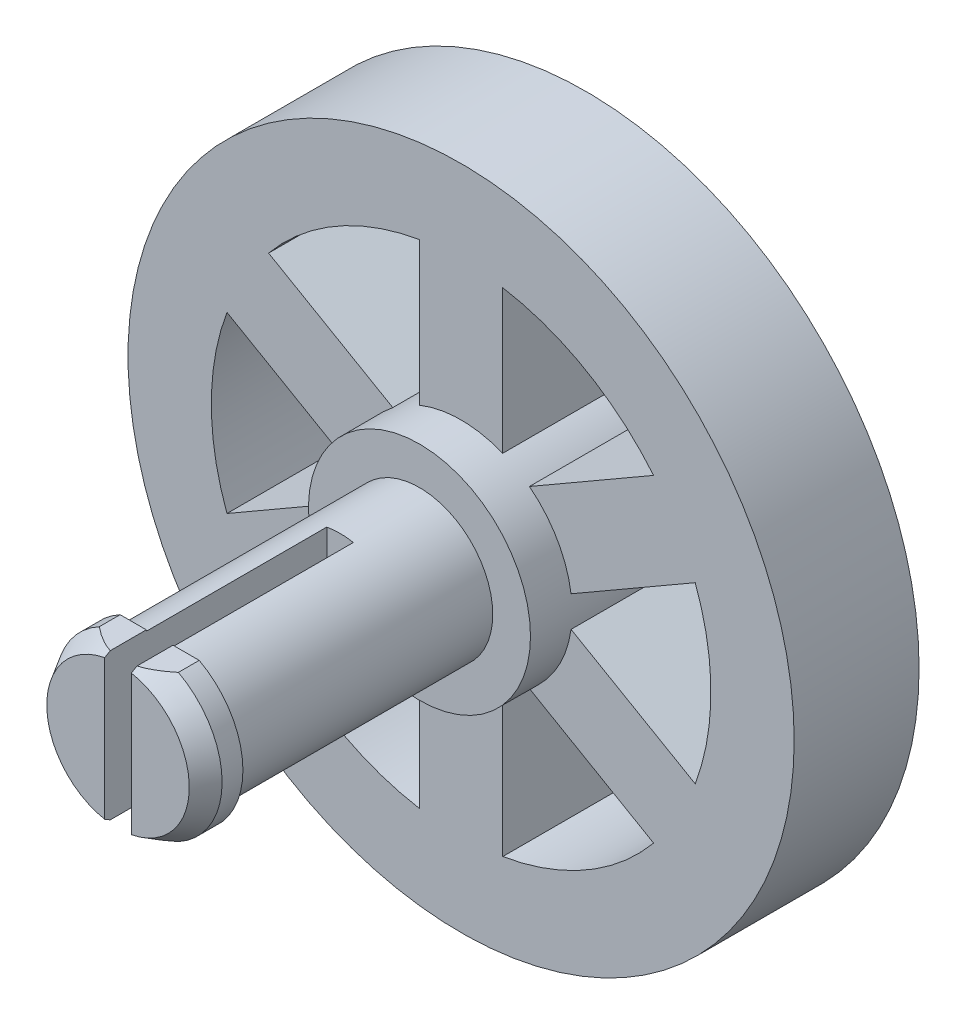
from build123d import *

# Parameters (mm, degrees)
BOSS_EXTRUDE1_DEPTH = 6.35
BOSS_EXTRUDE2_DEPTH = 4.7625
SKETCH1_4_R         = 12.7
BOSS_EXTRUDE3_DEPTH = 4.7625
SKETCH2_R           = 2.794
BOSS_EXTRUDE4_DEPTH = 9.906
SKETCH3_R           = 3.175
BOSS_EXTRUDE5_DEPTH = 1.5875
SKETCH4_W           = 8.466666667
SKETCH4_H           = 6.35
CUT_EXTRUDE1_DEPTH  = 0.508
SKETCH5_W           = 6.35
SKETCH5_H           = 1.439333333
SKETCH5_W_2         = 8.466666666
CUT_EXTRUDE2_DEPTH  = 1.5875
CHAMFER1_SIZE       = 0.79375
CHAMFER1_SIZE2      = 0.458271776
CHAMFER2_SIZE       = 0.79375
CHAMFER2_SIZE2      = 0.458271776


with BuildPart() as part:
    # Sketch1 → Boss-Extrude1 (new body)
    with BuildSketch(Plane.XY):
        with BuildLine():
            ThreePointArc((1.5875, 3.924405033), (0, 4.233333333), (-1.5875, 3.924405033))
            ThreePointArc((-1.5875, 3.924405033), (-2.116666667, 3.666174209), (-2.604884453, 3.337017845))
            ThreePointArc((-2.604884453, 3.337017845), (-3.666174209, 2.116666667), (-4.192384453, 0.587387188))
            ThreePointArc((-4.192384453, 0.587387188), (-4.233333333, 0), (-4.192384453, -0.587387188))
            ThreePointArc((-4.192384453, -0.587387188), (-3.666174209, -2.116666667), (-2.604884453, -3.337017845))
            ThreePointArc((-2.604884453, -3.337017845), (-2.116666667, -3.666174209), (-1.5875, -3.924405033))
            ThreePointArc((-1.5875, -3.924405033), (0, -4.233333333), (1.5875, -3.924405033))
            ThreePointArc((1.5875, -3.924405033), (2.116666667, -3.666174209), (2.604884453, -3.337017845))
            ThreePointArc((2.604884453, -3.337017845), (3.666174209, -2.116666667), (4.192384453, -0.587387188))
            ThreePointArc((4.192384453, -0.587387188), (4.223083705, -0.294406402), (4.233333333, 0))
            ThreePointArc((4.233333333, 0), (4.223083705, 0.294406402), (4.192384453, 0.587387188))
            ThreePointArc((4.192384453, 0.587387188), (3.666174209, 2.116666667), (2.604884453, 3.337017845))
            ThreePointArc((2.604884453, 3.337017845), (2.116666667, 3.666174209), (1.5875, 3.924405033))
        make_face()
    extrude(amount=BOSS_EXTRUDE1_DEPTH)

    # Sketch1_3 → Boss-Extrude2 (add)
    with BuildSketch(Plane.XY):
        with BuildLine():
            Line((-1.5875, 9.391776656), (-1.5875, 3.924405033))
            ThreePointArc((-1.5875, 3.924405033), (0, 4.233333333), (1.5875, 3.924405033))
            Line((1.5875, 3.924405033), (1.5875, 9.391776656))
            ThreePointArc((1.5875, 9.391776656), (0, 9.525), (-1.5875, 9.391776656))
        make_face()
        with BuildLine():
            ThreePointArc((-4.192384453, 0.587387188), (-3.666174209, 2.116666667), (-2.604884453, 3.337017845))
            Line((-2.604884453, 3.337017845), (-7.33976717, 6.070703656))
            ThreePointArc((-7.33976717, 6.070703656), (-8.248891971, 4.7625), (-8.92726717, 3.321072999))
            Line((-8.92726717, 3.321072999), (-4.192384453, 0.587387188))
        make_face()
        with BuildLine():
            Line((7.33976717, 6.070703656), (2.604884453, 3.337017845))
            ThreePointArc((2.604884453, 3.337017845), (3.666174209, 2.116666667), (4.192384453, 0.587387188))
            Line((4.192384453, 0.587387188), (8.92726717, 3.321072999))
            ThreePointArc((8.92726717, 3.321072999), (8.248891971, 4.7625), (7.33976717, 6.070703656))
        make_face()
        with BuildLine():
            ThreePointArc((-2.604884453, -3.337017845), (-3.666174209, -2.116666667), (-4.192384453, -0.587387188))
            Line((-4.192384453, -0.587387188), (-8.92726717, -3.321072999))
            ThreePointArc((-8.92726717, -3.321072999), (-8.248891971, -4.7625), (-7.33976717, -6.070703656))
            Line((-7.33976717, -6.070703656), (-2.604884453, -3.337017845))
        make_face()
        with BuildLine():
            Line((8.92726717, -3.321072999), (4.192384453, -0.587387188))
            ThreePointArc((4.192384453, -0.587387188), (3.666174209, -2.116666667), (2.604884453, -3.337017845))
            Line((2.604884453, -3.337017845), (7.33976717, -6.070703656))
            ThreePointArc((7.33976717, -6.070703656), (8.248891971, -4.7625), (8.92726717, -3.321072999))
        make_face()
        with BuildLine():
            ThreePointArc((1.5875, -3.924405033), (0, -4.233333333), (-1.5875, -3.924405033))
            Line((-1.5875, -3.924405033), (-1.5875, -9.391776656))
            ThreePointArc((-1.5875, -9.391776656), (0, -9.525), (1.5875, -9.391776656))
            Line((1.5875, -9.391776656), (1.5875, -3.924405033))
        make_face()
    extrude(amount=BOSS_EXTRUDE2_DEPTH)

    # Sketch1_4 → Boss-Extrude3 (add)
    with BuildSketch(Plane.XY):
        Circle(SKETCH1_4_R)
        with BuildLine():
            ThreePointArc((-7.33976717, 6.070703656), (-4.7625, 8.248891971), (-1.5875, 9.391776656))
            ThreePointArc((-1.5875, 9.391776656), (0, 9.525), (1.5875, 9.391776656))
            ThreePointArc((1.5875, 9.391776656), (4.7625, 8.248891971), (7.33976717, 6.070703656))
            ThreePointArc((7.33976717, 6.070703656), (8.248891971, 4.7625), (8.92726717, 3.321072999))
            ThreePointArc((8.92726717, 3.321072999), (9.374375841, 1.687217414), (9.525, 0))
            ThreePointArc((9.525, 0), (9.374375841, -1.687217414), (8.92726717, -3.321072999))
            ThreePointArc((8.92726717, -3.321072999), (8.248891971, -4.7625), (7.33976717, -6.070703656))
            ThreePointArc((7.33976717, -6.070703656), (4.7625, -8.248891971), (1.5875, -9.391776656))
            ThreePointArc((1.5875, -9.391776656), (0, -9.525), (-1.5875, -9.391776656))
            ThreePointArc((-1.5875, -9.391776656), (-4.7625, -8.248891971), (-7.33976717, -6.070703656))
            ThreePointArc((-7.33976717, -6.070703656), (-8.248891971, -4.7625), (-8.92726717, -3.321072999))
            ThreePointArc((-8.92726717, -3.321072999), (-9.525, 0), (-8.92726717, 3.321072999))
            ThreePointArc((-8.92726717, 3.321072999), (-8.248891971, 4.7625), (-7.33976717, 6.070703656))
        make_face(mode=Mode.SUBTRACT)
    extrude(amount=BOSS_EXTRUDE3_DEPTH)

    # Sketch2 → Boss-Extrude4 (add)
    with BuildSketch(Plane.XY.offset(6.35)):
        Circle(SKETCH2_R)
    extrude(amount=BOSS_EXTRUDE4_DEPTH)

    # Sketch3 → Boss-Extrude5 (add)
    with BuildSketch(Plane.XY.offset(16.256)):
        Circle(SKETCH3_R)
    extrude(amount=BOSS_EXTRUDE5_DEPTH)

    # Sketch4 → Cut-Extrude1 (cut, symmetric)
    with BuildSketch(Plane(origin=(0, 0, 0), x_dir=(0, 0, -1), z_dir=(1, 0, 0))):
        with Locations((-13.610166667, 0)):
            Rectangle(SKETCH4_W, SKETCH4_H)
    extrude(amount=CUT_EXTRUDE1_DEPTH, both=True, mode=Mode.SUBTRACT)

    # Sketch5 → Cut-Extrude2 (cut)
    with BuildSketch(Plane.XY.offset(17.8435)):
        with Locations((0, 3.513666666)):
            Rectangle(SKETCH5_W, SKETCH5_H)
        with Locations((0, -3.513666666)):
            Rectangle(SKETCH5_W_2, SKETCH5_H)
    extrude(amount=-CUT_EXTRUDE2_DEPTH, mode=Mode.SUBTRACT)

    # Chamfer1
    chamfer1_edges = [part.edges().sort_by_distance(p)[0] for p in [
        (-3.175, 0, 17.8435),
    ]]
    chamfer1_side = [part.faces().sort_by_distance(p)[0] for p in [
        (-3.175, 0, 17.04975),
    ]]
    chamfer(chamfer1_edges, length=CHAMFER1_SIZE, length2=CHAMFER1_SIZE2, reference=chamfer1_side[0])

    # Chamfer2
    chamfer2_edges = [part.edges().sort_by_distance(p)[0] for p in [
        (3.175, 0, 17.8435),
    ]]
    chamfer2_side = [part.faces().sort_by_distance(p)[0] for p in [
        (3.175, 0, 17.04975),
    ]]
    chamfer(chamfer2_edges, length=CHAMFER2_SIZE, length2=CHAMFER2_SIZE2, reference=chamfer2_side[0])


solid = part.part
